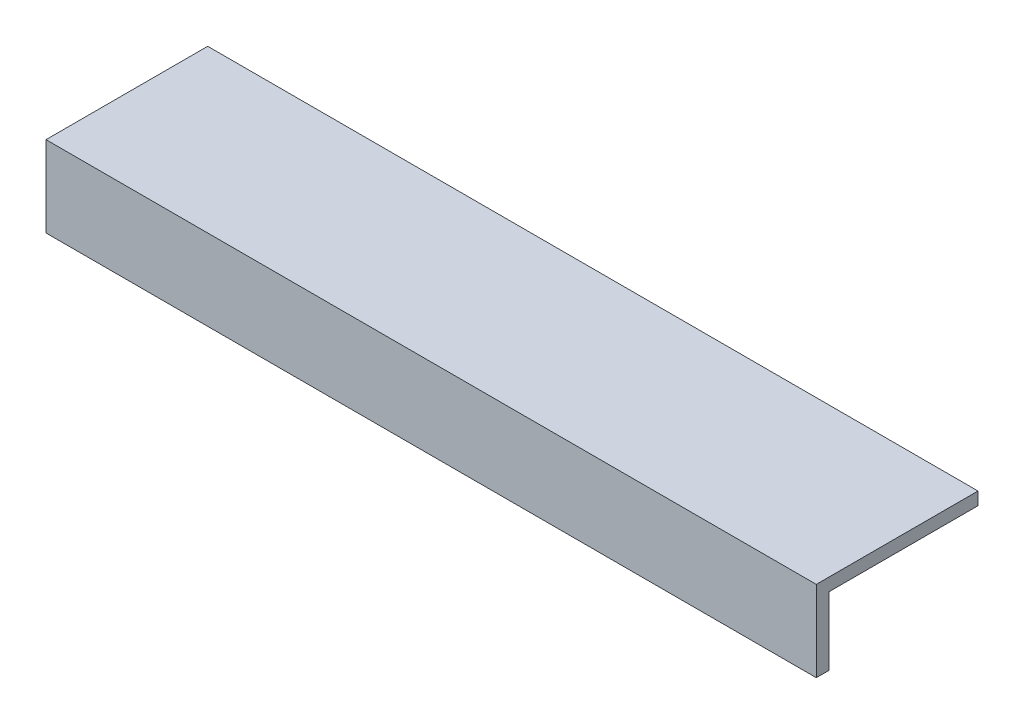
from build123d import *

# Parameters (mm, degrees)
SALIENTE_EXTRUIR1_DEPTH = 181
CROQUIS2_W              = 181
CROQUIS2_H              = 19
CORTAR_EXTRUIR1_DEPTH   = 3


with BuildPart() as part:
    # Croquis1 → Saliente-Extruir1 (new body)
    with BuildSketch(Plane(origin=(0, 0, 0), x_dir=(0, 0, -1), z_dir=(1, 0, 0))):
        Polygon((0, 0), (0, -38), (3, -38), (3, -3), (38, -3), (38, 0), align=None)
    extrude(amount=SALIENTE_EXTRUIR1_DEPTH)

    # Croquis2 → Cortar-Extruir1 (cut)
    with BuildSketch(Plane.XY):
        with Locations((90.5, -28.5)):
            Rectangle(CROQUIS2_W, CROQUIS2_H)
    extrude(amount=-CORTAR_EXTRUIR1_DEPTH, mode=Mode.SUBTRACT)


solid = part.part
